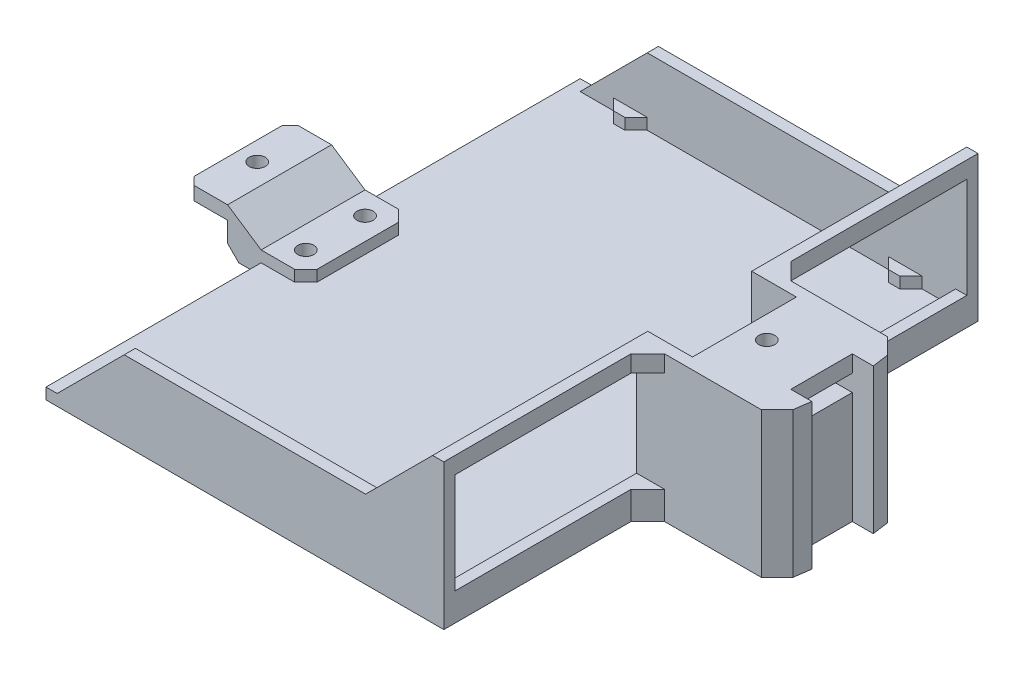
from build123d import *

# Parameters (mm, degrees)
SKETCH3_W                                       = 90.422573022
SKETCH3_H                                       = 121.412
BOSS_EXTRUDE4_DEPTH                             = 2.54
BOSS_EXTRUDE5_DEPTH                             = 30.48
CUT_EXTRUDE2_DEPTH                              = 122.412
BOSS_EXTRUDE6_DEPTH                             = 33.02
SKETCH9_W                                       = 10.16
SKETCH9_H                                       = 23.622
CUT_EXTRUDE3_DEPTH                              = 27.94
BOSS_EXTRUDE7_DEPTH                             = 2.54
SKETCH12_W                                      = 23.622
SKETCH12_H                                      = 3.81
CUT_EXTRUDE4_DEPTH                              = 10.16
SKETCH13_W                                      = 13.97
SKETCH13_H                                      = 3.81
CUT_EXTRUDE5_DEPTH                              = 13.141913489
BOSS_EXTRUDE9_REACH                             = 62.706
BOSS_EXTRUDE9_DIRECTION_2_REACH                 = 62.706
CBORE_FOR_6_PAN_HEAD_MACHINE_SCREW1_D           = 3.6576
CBORE_FOR_6_PAN_HEAD_MACHINE_SCREW1_CBORE_D     = 7.54126
CBORE_FOR_6_PAN_HEAD_MACHINE_SCREW1_CBORE_DEPTH = 2.4638
F_6_CLEARANCE_HOLE1_D                           = 3.6576
SKETCH21_W                                      = 43.815
SKETCH21_H                                      = 22.86
CUT_EXTRUDE6_DEPTH                              = 33.461913489
CHAMFER1_SIZE                                   = 2.54
CHAMFER2_SIZE                                   = 3.81
SKETCH23_W                                      = 10.16
SKETCH23_H                                      = 23.622
CUT_EXTRUDE8_DEPTH                              = 0.762
CHAMFER3_SIZE                                   = 0.762


with BuildPart() as part:
    # Sketch3 → Boss-Extrude4 (new body)
    with BuildSketch(Plane(origin=(0, 0, 0), x_dir=(1, 0, 0), z_dir=(0, 1, 0))):
        Rectangle(SKETCH3_W, SKETCH3_H)
    extrude(amount=BOSS_EXTRUDE4_DEPTH)

    # Sketch6 → Boss-Extrude5 (add)
    with BuildSketch(Plane(origin=(0, 2.54, 0), x_dir=(1, 0, 0), z_dir=(0, 1, 0))):
        Polygon((45.211286511, -60.706), (45.211286511, 60.706), (-45.211286511, 60.706), (-45.211286511, 58.166), (42.671286511, 58.166), (42.671286511, -58.166), (-45.211286511, -58.166), (-45.211286511, -60.706), align=None)
    extrude(amount=BOSS_EXTRUDE5_DEPTH)

    # Sketch7 → Cut-Extrude2 (cut, through all)
    with BuildSketch(Plane.XY.offset(60.706)):
        Polygon((-42.671286511, 2.54), (-27.431286511, 17.78), (27.431286511, 17.78), (42.671286511, 33.02), (-45.211286511, 33.02), (-45.211286511, 2.54), align=None)
    extrude(amount=-CUT_EXTRUDE2_DEPTH, mode=Mode.SUBTRACT)

    # Sketch8 → Boss-Extrude6 (add)
    with BuildSketch(Plane(origin=(0, 0, 0), x_dir=(1, 0, 0), z_dir=(0, 1, 0))):
        Polygon((45.211286511, 14.351), (71.009871827, 14.351), (74.602950485, 10.757921342), (75.1332, 6.985), (70.358, 6.985), (70.358, -6.985), (75.1332, -6.985), (74.602950485, -10.757921342), (71.009871827, -14.351), (45.211286511, -14.351), align=None)
    extrude(amount=BOSS_EXTRUDE6_DEPTH)

    # Sketch9 → Cut-Extrude3 (cut)
    with BuildSketch(Plane(origin=(0, 33.02, 0), x_dir=(1, 0, 0), z_dir=(0, 1, 0))):
        with Locations((47.751286511, 0)):
            Rectangle(SKETCH9_W, SKETCH9_H)
    extrude(amount=-CUT_EXTRUDE3_DEPTH, mode=Mode.SUBTRACT)

    # Sketch11 → Boss-Extrude7 (add)
    with BuildSketch(Plane(origin=(0, 2.54, 0), x_dir=(1, 0, 0), z_dir=(0, 1, 0))):
        Polygon((35.051286511, 58.166), (27.431286511, 58.166), (29.971286511, 55.626), (32.511286511, 55.626), align=None)
        Polygon((-29.971286511, 55.626), (-32.511286511, 55.626), (-35.051286511, 58.166), (-27.431286511, 58.166), align=None)
        Polygon((29.971286511, -55.626), (32.511286511, -55.626), (35.051286511, -58.166), (27.431286511, -58.166), align=None)
        Polygon((-27.431286511, -58.166), (-29.971286511, -55.626), (-32.511286511, -55.626), (-35.051286511, -58.166), align=None)
    extrude(amount=BOSS_EXTRUDE7_DEPTH)

    # Sketch12 → Cut-Extrude4 (cut)
    with BuildSketch(Plane.ZY.offset(-52.831286511)):
        with Locations((0, 27.305)):
            Rectangle(SKETCH12_W, SKETCH12_H)
    extrude(amount=-CUT_EXTRUDE4_DEPTH, mode=Mode.SUBTRACT)

    # Sketch13 → Cut-Extrude5 (cut, through all)
    with BuildSketch(Plane.ZY.offset(-62.991286511)):
        with Locations((0, 27.305)):
            Rectangle(SKETCH13_W, SKETCH13_H)
    extrude(amount=-CUT_EXTRUDE5_DEPTH, mode=Mode.SUBTRACT)

    # Boss-Extrude9: up to this face of the body (flat: up to its plane)
    boss_extrude9_end = Plane(part.part.faces().sort_by_distance((48.970486511, 20.0406, -11.811))[0])
    # Sketch15 → Boss-Extrude9 (add, up to the picked face)
    with BuildSketch(Plane.XY, mode=Mode.PRIVATE) as boss_extrude9_sk1:
        Polygon((-62.991286511, 10.16), (-52.831286511, 10.16), (-45.211286511, 5.08), (-35.051286511, 5.08), (-35.051286511, 2.54), (-45.211286511, 2.54), (-45.211286511, 0), (-52.831286511, 0), (-52.831286511, 6.35), (-62.991286511, 6.35), align=None)
    boss_extrude9_tool1 = split(extrude(boss_extrude9_sk1.sketch, amount=-BOSS_EXTRUDE9_REACH, mode=Mode.PRIVATE), bisect_by=boss_extrude9_end, keep=Keep.BOTH, mode=Mode.PRIVATE)
    add(boss_extrude9_tool1.solids().sort_by_distance((-50.157602, 5.280526, 0))[0])

    # Boss-Extrude9 direction 2: up to this face of the body (flat: up to its plane)
    boss_extrude9_direction_2_end = Plane(part.part.faces().sort_by_distance((48.970486511, 20.0406, 11.811))[0])
    # Sketch15 → Boss-Extrude9 direction 2 (add, up to the picked face)
    with BuildSketch(Plane.XY, mode=Mode.PRIVATE) as boss_extrude9_direction_2_sk1:
        Polygon((-62.991286511, 10.16), (-52.831286511, 10.16), (-45.211286511, 5.08), (-35.051286511, 5.08), (-35.051286511, 2.54), (-45.211286511, 2.54), (-45.211286511, 0), (-52.831286511, 0), (-52.831286511, 6.35), (-62.991286511, 6.35), align=None)
    boss_extrude9_direction_2_tool1 = split(extrude(boss_extrude9_direction_2_sk1.sketch, amount=BOSS_EXTRUDE9_DIRECTION_2_REACH, mode=Mode.PRIVATE), bisect_by=boss_extrude9_direction_2_end, keep=Keep.BOTH, mode=Mode.PRIVATE)
    add(boss_extrude9_direction_2_tool1.solids().sort_by_distance((-50.157602, 5.280526, 0))[0])

    # CBORE for #6 Pan Head Machine Screw1 (through all)
    with Locations(Plane(origin=(0, 0, 0), x_dir=(-1, 0, 0), z_dir=(0, -1, 0))):
        with Locations((-47.751286511, 6.731), (-47.751286511, -6.731), (40.131286511, 6.731), (40.131286511, -6.731)):
            CounterBoreHole(CBORE_FOR_6_PAN_HEAD_MACHINE_SCREW1_D / 2, CBORE_FOR_6_PAN_HEAD_MACHINE_SCREW1_CBORE_D / 2, CBORE_FOR_6_PAN_HEAD_MACHINE_SCREW1_CBORE_DEPTH)

    # #6 Clearance Hole1 (through all)
    with Locations(Plane(origin=(0, 33.02, 0), x_dir=(1, 0, 0), z_dir=(0, 1, 0))):
        with Locations((-57.911286511, 0), (57.911286511, 0)):
            Hole(F_6_CLEARANCE_HOLE1_D / 2)

    # Sketch21 → Cut-Extrude6 (cut, through all)
    with BuildSketch(Plane.ZY.offset(-42.671286511)):
        with Locations((-36.2585, 17.78)):
            Rectangle(SKETCH21_W, SKETCH21_H)
        with Locations((36.2585, 17.78)):
            Rectangle(SKETCH21_W, SKETCH21_H)
    extrude(amount=-CUT_EXTRUDE6_DEPTH, mode=Mode.SUBTRACT)

    # Chamfer1
    chamfer1_edges = [part.edges().sort_by_distance(p)[0] for p in [
        (-52.831286511, 0, 0),
        (-35.051286511, 3.81, -11.811),
        (-62.991286511, 8.255, -11.811),
        (-62.991286511, 8.255, 11.811),
        (-35.051286511, 3.81, 11.811),
    ]]
    chamfer(chamfer1_edges, length=CHAMFER1_SIZE)

    # Chamfer2
    chamfer2_edges = [part.edges().sort_by_distance(p)[0] for p in [
        (45.211286511, 3.175, -14.351),
        (45.211286511, 3.175, 14.351),
        (45.211286511, 31.115, -14.351),
        (45.211286511, 31.115, 14.351),
    ]]
    chamfer(chamfer2_edges, length=CHAMFER2_SIZE)

    # Sketch23 → Cut-Extrude8 (cut)
    with BuildSketch(Plane.XZ.offset(-6.35)):
        with Locations((-57.911286511, 0)):
            Rectangle(SKETCH23_W, SKETCH23_H)
    extrude(amount=-CUT_EXTRUDE8_DEPTH, mode=Mode.SUBTRACT)

    # Chamfer3
    chamfer3_edges = [part.edges().sort_by_distance(p)[0] for p in [
        (-62.991286511, 10.16, 0),
        (-62.991286511, 7.112, 0),
    ]]
    chamfer(chamfer3_edges, length=CHAMFER3_SIZE)


solid = part.part
